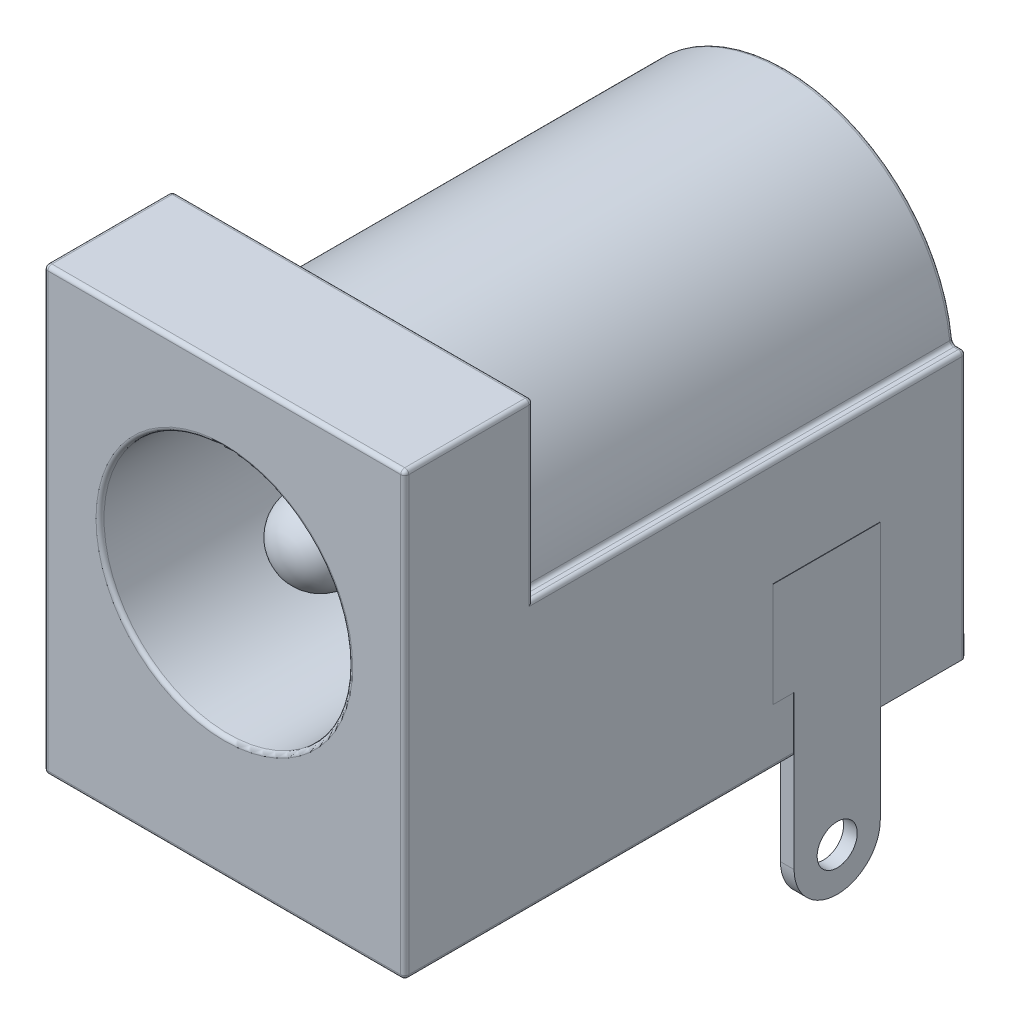
from build123d import *

# Parameters (mm, degrees)
SKETCH1_W                = 9
SKETCH1_H                = 11
SKETCH1_R                = 3.1
BOSS_EXTRUDE1_DEPTH      = 14
CUT_EXTRUDE1_DEPTH       = 10.8
BOSS_EXTRUDE2_DEPTH      = 1
SKETCH4_R                = 1
BOSS_EXTRUDE3_DEPTH      = 11.6
FILLET1_R                = 1
SKETCH5_R                = 0.5
BOSS_EXTRUDE4_DEPTH      = 0.01
BOSS_EXTRUDE4_DEPTH_BACK = 0.33
SKETCH6_R                = 0.5
BOSS_EXTRUDE5_DEPTH      = 0.01
BOSS_EXTRUDE5_DEPTH_BACK = 0.33
SKETCH8_R                = 0.5
BOSS_EXTRUDE6_DEPTH      = 0.33
FILLET2_R                = 0.1


with BuildPart() as part:
    # Sketch1 → Boss-Extrude1 (new body)
    with BuildSketch(Plane.XY):
        Rectangle(SKETCH1_W, SKETCH1_H)
        with Locations((0, 0.65)):
            Circle(SKETCH1_R, mode=Mode.SUBTRACT)
    extrude(amount=-BOSS_EXTRUDE1_DEPTH)

    # Sketch2 → Cut-Extrude1 (cut)
    with BuildSketch(Plane(origin=(0, 0, -14), x_dir=(-1, 0, 0), z_dir=(0, 0, -1))):
        with BuildLine():
            Line((-4.5, 5.5), (4.5, 5.5))
            Line((4.5, 5.5), (4.5, 1.15))
            Line((4.5, 1.15), (4.2, 1.15))
            ThreePointArc((4.2, 1.15), (0, 5), (-4.2, 1.15))
            Line((-4.2, 1.15), (-4.5, 1.15))
            Line((-4.5, 1.15), (-4.5, 5.5))
        make_face()
    extrude(amount=-CUT_EXTRUDE1_DEPTH, mode=Mode.SUBTRACT)

    # Sketch3 → Boss-Extrude2 (add)
    with BuildSketch(Plane(origin=(0, 0, -14), x_dir=(-1, 0, 0), z_dir=(0, 0, -1))):
        with BuildLine():
            Line((-4.5, 1.15), (-4.5, -5.5))
            Line((-4.5, -5.5), (4.5, -5.5))
            Line((4.5, -5.5), (4.5, 1.15))
            Line((4.5, 1.15), (4.2, 1.15))
            ThreePointArc((4.2, 1.15), (0, 5), (-4.2, 1.15))
            Line((-4.2, 1.15), (-4.5, 1.15))
        make_face()
    extrude(amount=-BOSS_EXTRUDE2_DEPTH)

    # Sketch4 → Boss-Extrude3 (add)
    with BuildSketch(Plane.XY.offset(-13)):
        with Locations((0, 0.65)):
            Circle(SKETCH4_R)
    extrude(amount=BOSS_EXTRUDE3_DEPTH)

    # Fillet1
    fillet1_edges = [part.edges().sort_by_distance(p)[0] for p in [
        (-1, 0.65, -1.4),
    ]]
    fillet(fillet1_edges, radius=FILLET1_R)

    # Sketch5 → Boss-Extrude4 (add, two sides)
    with BuildSketch(Plane(origin=(0, 0, -14), x_dir=(-1, 0, 0), z_dir=(0, 0, -1))) as boss_extrude4_sk:
        with BuildLine():
            Line((1.5, 2.472875656), (-1.5, 2.472875656))
            ThreePointArc((-1.5, 2.472875656), (-2, 1.15), (-1.5, -0.172875656))
            Line((-1.5, -0.172875656), (-1.5, -4.35))
            ThreePointArc((-1.5, -4.35), (-1.456066017, -4.456066017), (-1.35, -4.5))
            Line((-1.35, -4.5), (-1.315, -4.5))
            ThreePointArc((-1.315, -4.5), (-1.208933983, -4.543933983), (-1.165, -4.65))
            Line((-1.165, -4.65), (-1.165, -7.835))
            ThreePointArc((-1.165, -7.835), (0, -9), (1.165, -7.835))
            Line((1.165, -7.835), (1.165, -4.65))
            ThreePointArc((1.165, -4.65), (1.208933983, -4.543933983), (1.315, -4.5))
            Line((1.315, -4.5), (1.35, -4.5))
            ThreePointArc((1.35, -4.5), (1.456066017, -4.456066017), (1.5, -4.35))
            Line((1.5, -4.35), (1.5, -0.172875656))
            ThreePointArc((1.5, -0.172875656), (2, 1.15), (1.5, 2.472875656))
        make_face()
        with Locations((0, -7.835)):
            Circle(SKETCH5_R, mode=Mode.SUBTRACT)
    extrude(amount=BOSS_EXTRUDE4_DEPTH)
    extrude(boss_extrude4_sk.sketch, amount=-BOSS_EXTRUDE4_DEPTH_BACK)

    # Sketch6 → Boss-Extrude5 (add, two sides)
    with BuildSketch(Plane(origin=(4.5, 0, 0), x_dir=(0, 0, -1), z_dir=(1, 0, 0))) as boss_extrude5_sk:
        with BuildLine():
            Line((11.85, -7.925), (11.85, -1.5))
            Line((11.85, -1.5), (9.18, -1.5))
            Line((9.18, -1.5), (9.18, -4.1))
            Line((9.18, -4.1), (9.7, -4.1))
            Line((9.7, -4.1), (9.7, -7.925))
            ThreePointArc((9.7, -7.925), (10.775, -9), (11.85, -7.925))
        make_face()
        with Locations((10.775, -7.925)):
            Circle(SKETCH6_R, mode=Mode.SUBTRACT)
    extrude(amount=BOSS_EXTRUDE5_DEPTH)
    extrude(boss_extrude5_sk.sketch, amount=-BOSS_EXTRUDE5_DEPTH_BACK)

    # Sketch8 → Boss-Extrude6 (add)
    with BuildSketch(Plane(origin=(0, 0, -7.2), x_dir=(-1, 0, 0), z_dir=(0, 0, -1))):
        with BuildLine():
            Line((-1.165, -5.5), (1.165, -5.5))
            Line((1.165, -5.5), (1.165, -7.835))
            ThreePointArc((1.165, -7.835), (0, -9), (-1.165, -7.835))
            Line((-1.165, -7.835), (-1.165, -5.5))
        make_face()
        with Locations((0, -7.835)):
            Circle(SKETCH8_R, mode=Mode.SUBTRACT)
    extrude(amount=BOSS_EXTRUDE6_DEPTH)

    # Fillet2
    fillet2_edges = [part.edges().sort_by_distance(p)[0] for p in [
        (4.35, 1.15, -14),
        (-4.35, 1.15, -14),
        (-3.1, 0.65, 0),
        (4.5, 3.325, -3.2),
        (-4.5, 3.325, -3.2),
        (-4.5, -2.175, -14),
        (-2.8325, -5.5, -14),
        (2.8325, -5.5, -14),
        (4.5, -2.175, -14),
        (4.5, 1.15, -8.6),
        (4.2, 1.15, -8.6),
        (-4.2, 1.15, -8.6),
        (-4.5, 1.15, -8.6),
        (0, 5, -3.2),
        (0, 5, -14),
        (0, 5.5, -3.2),
        (0, 5.5, 0),
        (4.5, 0, 0),
        (-4.5, 0, 0),
        (-4.5, -5.5, -7),
        (0, -5.5, 0),
        (4.5, -5.5, -4.85),
        (-4.5, 5.5, -1.6),
        (4.5, 5.5, -1.6),
    ]]
    fillet(fillet2_edges, radius=FILLET2_R)


solid = part.part
